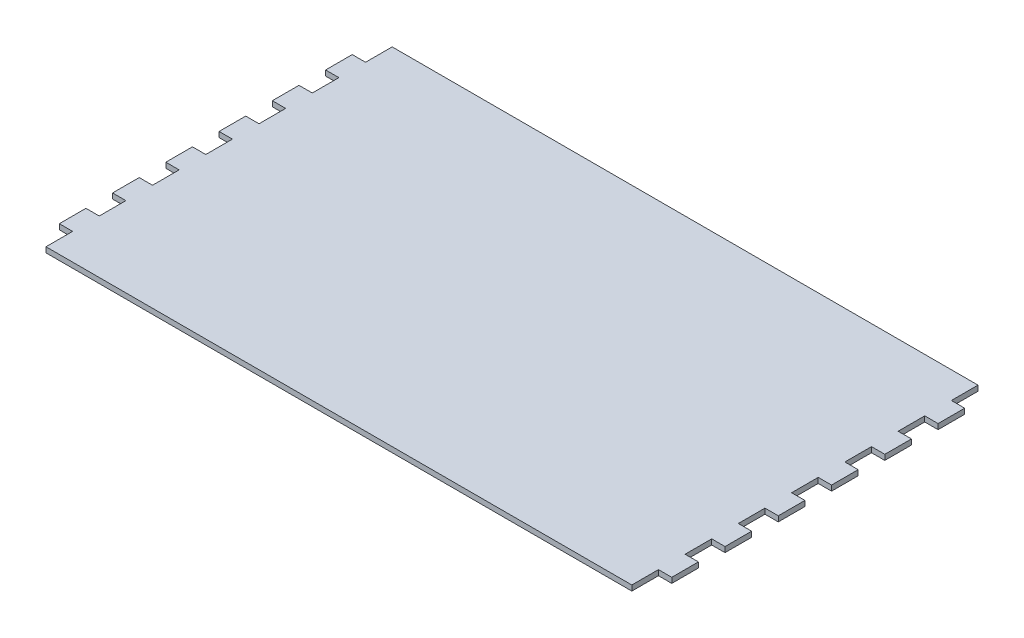
from build123d import *

# Parameters (mm, degrees)
BOSS_EXTRUDE1_DEPTH = 2.54


with BuildPart() as part:
    # Sketch1 → Boss-Extrude1 (new body)
    with BuildSketch(Plane(origin=(0, 0, 0), x_dir=(1, 0, 0), z_dir=(0, 1, 0))):
        Polygon((0, 0), (279.4, 0), (279.4, -12.7), (285.75, -12.7), (285.75, -25.4), (279.4, -25.4), (279.4, -38.1), (285.75, -38.1), (285.75, -50.8), (279.4, -50.8), (279.4, -63.5), (285.75, -63.5), (285.75, -76.2), (279.4, -76.2), (279.4, -88.9), (285.75, -88.9), (285.75, -101.6), (279.4, -101.6), (279.4, -114.3), (285.75, -114.3), (285.75, -127), (279.4, -127), (279.4, -139.7), (285.75, -139.7), (285.75, -152.4), (279.4, -152.4), (279.4, -165.1), (0, -165.1), (0, -152.4), (-6.35, -152.4), (-6.35, -139.7), (0, -139.7), (0, -127), (-6.35, -127), (-6.35, -114.3), (0, -114.3), (0, -101.6), (-6.35, -101.6), (-6.35, -88.9), (0, -88.9), (0, -76.2), (-6.35, -76.2), (-6.35, -63.5), (0, -63.5), (0, -50.8), (-6.35, -50.8), (-6.35, -38.1), (0, -38.1), (0, -25.4), (-6.35, -25.4), (-6.35, -12.7), (0, -12.7), align=None)
    extrude(amount=BOSS_EXTRUDE1_DEPTH)


solid = part.part
